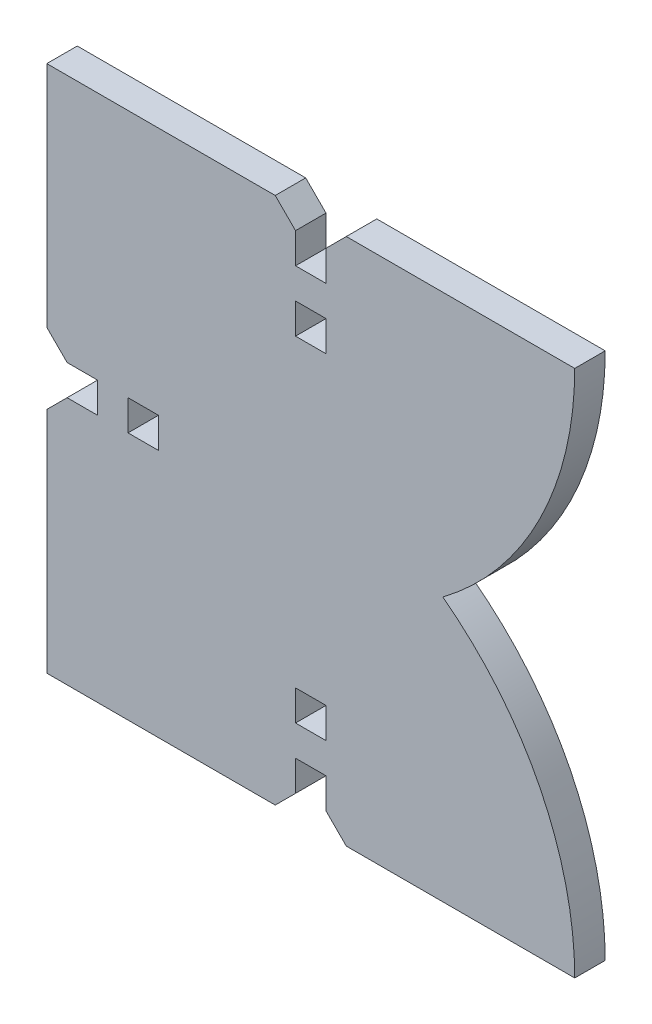
from build123d import *

# Parameters (mm, degrees)
BOSS_EXTRUDE1_DEPTH = 3
CIRPATTERN1_COUNT   = 4
CUT_EXTRUDE1_REACH  = 5


with BuildPart() as part:
    # Sketch1 → Boss-Extrude1 (new body)
    with BuildSketch(Plane.XY):
        Polygon((3.5, 26), (1.5, 24), (1.5, 21), (0, 21), (0, 18), (1.5, 18), (1.5, 15), (0, 15), (0, 12), (0, 9), (0, 6), (0, 3), (0, 0), (3, 0), (6, 0), (9, 0), (12, 0), (15, 0), (15, 1.5), (18, 1.5), (18, 0), (21, 0), (21, 1.5), (24, 1.5), (26, 3.5), (26, 26), align=None)
    boss_extrude1 = extrude(amount=BOSS_EXTRUDE1_DEPTH)

    # CirPattern1: Boss-Extrude1 ×4 about axis
    cirpattern1_axis = Axis((0, 0, 0), (0, 0, 1))
    for i in range(1, CIRPATTERN1_COUNT):
        add(boss_extrude1.rotate(cirpattern1_axis, i * 360 / CIRPATTERN1_COUNT))

    # Sketch2 → Cut-Extrude1 (cut, up to next)
    with BuildSketch(Plane.XY, mode=Mode.PRIVATE) as cut_extrude1_sk1:
        with BuildLine():
            Line((26, 26), (36, 26))
            Line((36, 26), (36, -26))
            Line((36, -26), (26, -26))
            ThreePointArc((26, -26), (22.568883707, -11.465558146), (13, 0))
            ThreePointArc((13, 0), (22.568883707, 11.465558146), (26, 26))
        make_face()
    cut_extrude1_tool1 = extrude(cut_extrude1_sk1.sketch, amount=CUT_EXTRUDE1_REACH, mode=Mode.PRIVATE) & part.part
    add(cut_extrude1_tool1.solids().sort_by_distance((28.547836, 0, 0))[0], mode=Mode.SUBTRACT)


solid = part.part
